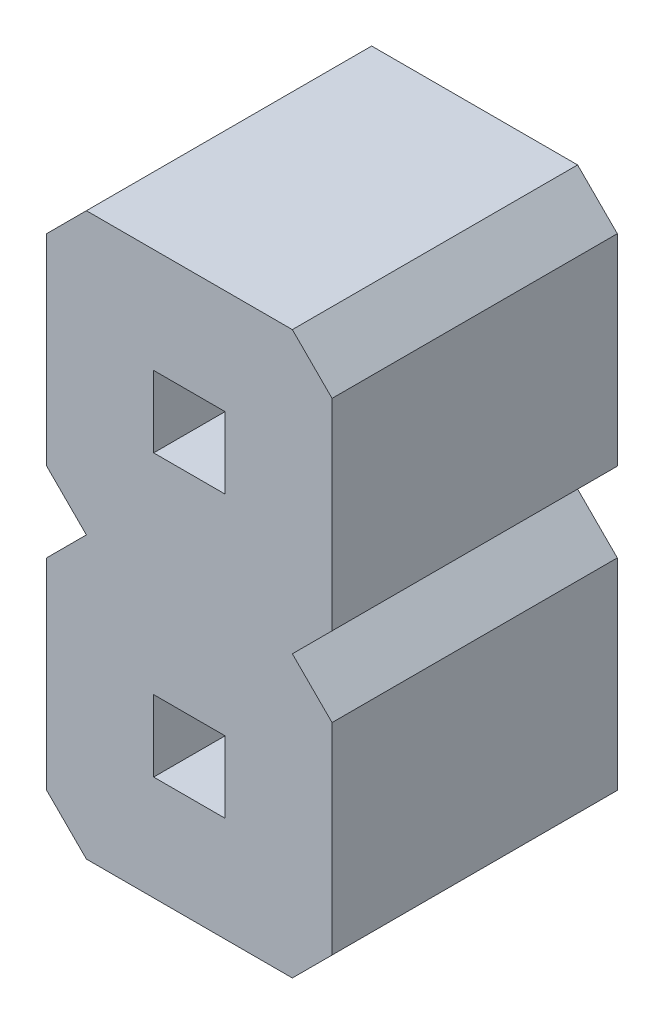
from build123d import *

# Parameters (mm, degrees)
PIN_BODY_W          = 0.636
PIN_BODY_H          = 0.636
BOSS_EXTRUDE1_DEPTH = 2.54


with BuildPart() as part:
    # pin_body → Boss-Extrude1 (new body)
    with BuildSketch(Plane.XY):
        Polygon((0, 2.146446609), (0, 0.353553391), (0.353553391, 0), (0, -0.353553391), (0, -2.146446609), (0.353553391, -2.5), (2.187446609, -2.5), (2.541, -2.146446609), (2.541, -0.353553391), (2.187446609, 0), (2.541, 0.353553391), (2.541, 2.146446609), (2.187446609, 2.5), (0.353553391, 2.5), align=None)
        with Locations((1.2705, -1.25)):
            Rectangle(PIN_BODY_W, PIN_BODY_H, mode=Mode.SUBTRACT)
        with Locations((1.2705, 1.25)):
            Rectangle(PIN_BODY_W, PIN_BODY_H, mode=Mode.SUBTRACT)
    extrude(amount=BOSS_EXTRUDE1_DEPTH)


solid = part.part
